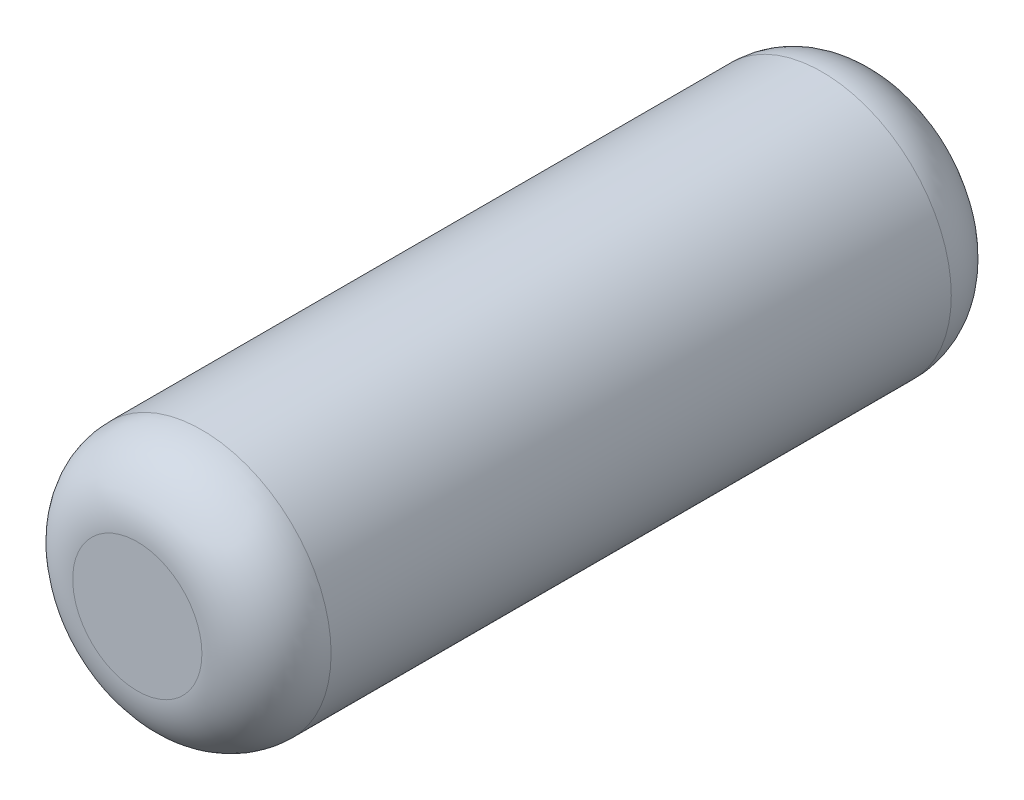
from build123d import *

# Parameters (mm, degrees)
CROQUIS2_R              = 5
SALIENTE_EXTRUIR1_DEPTH = 29
REDONDEO3_R             = 2.5


with BuildPart() as part:
    # Croquis2 → Saliente-Extruir1 (new body)
    with BuildSketch(Plane.XY):
        Circle(CROQUIS2_R)
    extrude(amount=SALIENTE_EXTRUIR1_DEPTH)

    # Redondeo3
    redondeo3_edges = [part.edges().sort_by_distance(p)[0] for p in [
        (-5, 0, 0),
        (-5, 0, 29),
    ]]
    fillet(redondeo3_edges, radius=REDONDEO3_R)


solid = part.part
